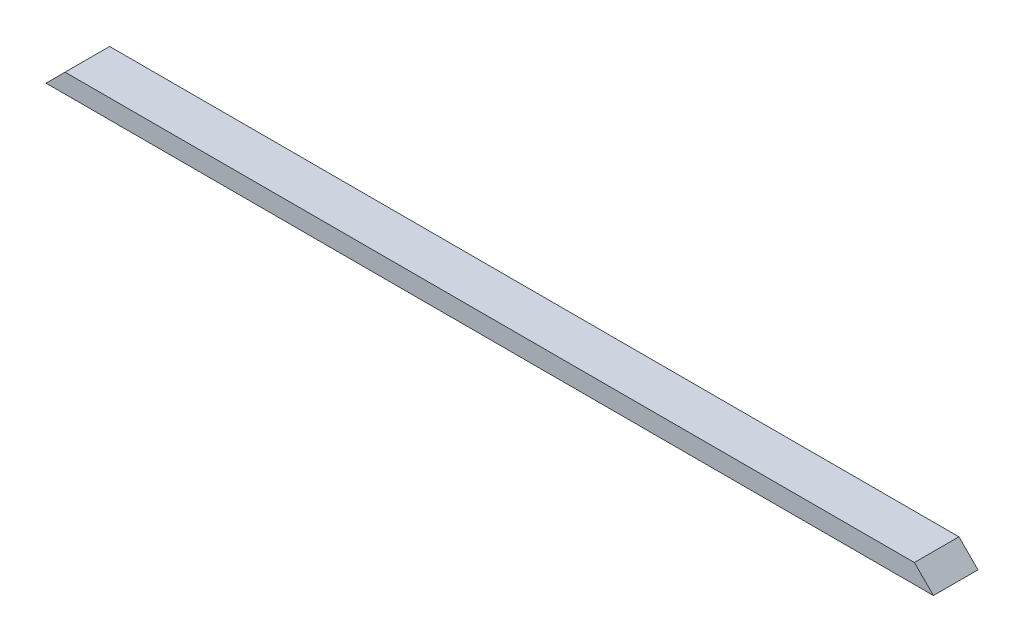
from build123d import *

# Parameters (mm, degrees)
SKETCH1_W           = 1771.65
SKETCH1_H           = 88.9
BOSS_EXTRUDE1_DEPTH = 38.1
CUT_EXTRUDE1_DEPTH  = 89.9


with BuildPart() as part:
    # Sketch1 → Boss-Extrude1 (new body)
    with BuildSketch(Plane(origin=(0, 0, 0), x_dir=(1, 0, 0), z_dir=(0, 1, 0))):
        with Locations((885.825, 44.45)):
            Rectangle(SKETCH1_W, SKETCH1_H)
    extrude(amount=BOSS_EXTRUDE1_DEPTH)

    # Sketch2 → Cut-Extrude1 (cut, through all)
    with BuildSketch(Plane.XY):
        Polygon((0, 0), (38.1, 38.1), (0, 38.1), align=None)
        Polygon((1771.65, 0), (1771.65, 38.1), (1733.55, 38.1), align=None)
    extrude(amount=-CUT_EXTRUDE1_DEPTH, mode=Mode.SUBTRACT)


solid = part.part
